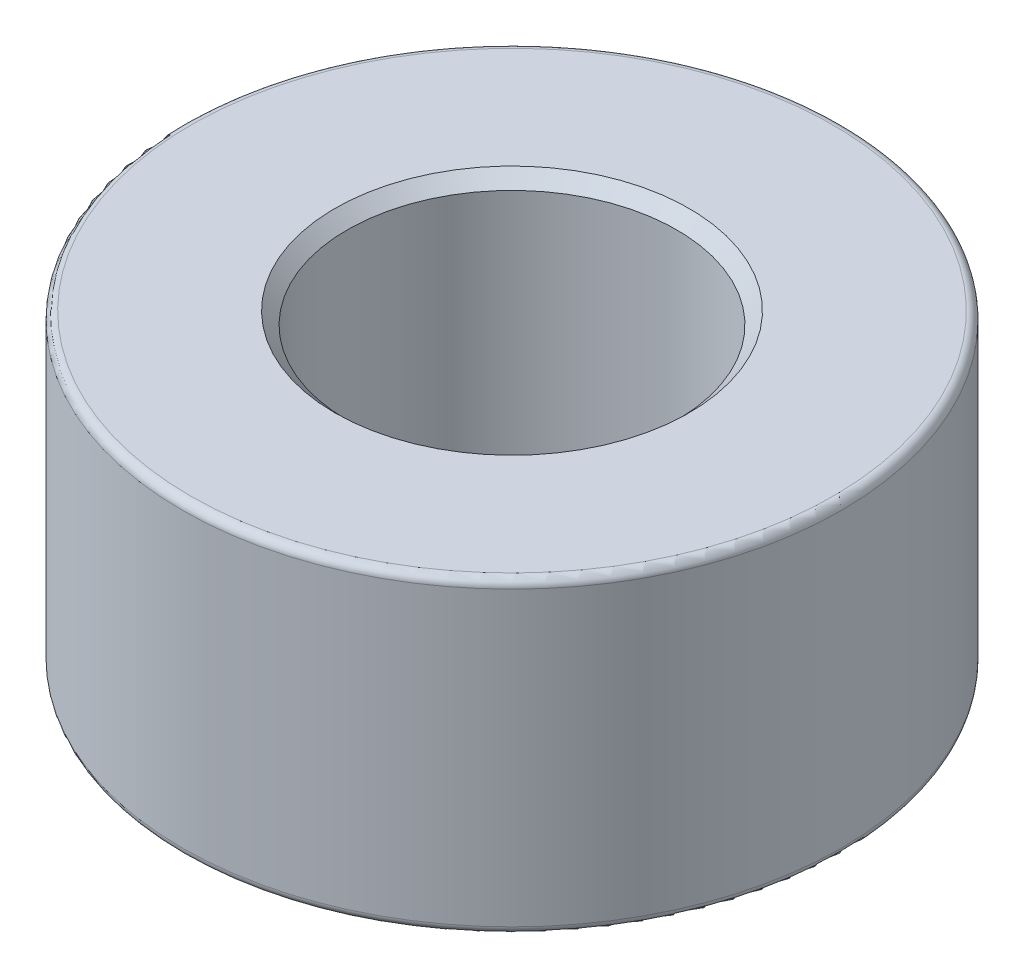
from build123d import *

# Parameters (mm, degrees)
BOSS_EXTRUDE1_DEPTH      = 1.875
BOSS_EXTRUDE1_DEPTH_BACK = 1.875
SKETCH1_R                = 4
SKETCH1_R_2              = 2
FILLET1_R                = 0.1
CHAMFER4_SIZE            = 0.15


with BuildPart() as part:
    # Sketch1 → Boss-Extrude1 (new, two sides: drawn at the far end of the back side and taken through both)
    with BuildSketch(Plane(origin=(0, 0, 0), x_dir=(1, 0, 0), z_dir=(0, 1, 0)).offset(-BOSS_EXTRUDE1_DEPTH_BACK)):
        Circle(SKETCH1_R)
        Circle(SKETCH1_R_2, mode=Mode.SUBTRACT)
    extrude(amount=BOSS_EXTRUDE1_DEPTH + BOSS_EXTRUDE1_DEPTH_BACK)

    # Fillet1
    fillet1_edges = [part.edges().sort_by_distance(p)[0] for p in [
        (-4, 1.875, 0),
        (-4, -1.875, 0),
    ]]
    fillet(fillet1_edges, radius=FILLET1_R)

    # Chamfer4
    chamfer4_edges = [part.edges().sort_by_distance(p)[0] for p in [
        (-2, -1.875, 0),
        (-2, 1.875, 0),
    ]]
    chamfer(chamfer4_edges, length=CHAMFER4_SIZE)


solid = part.part
